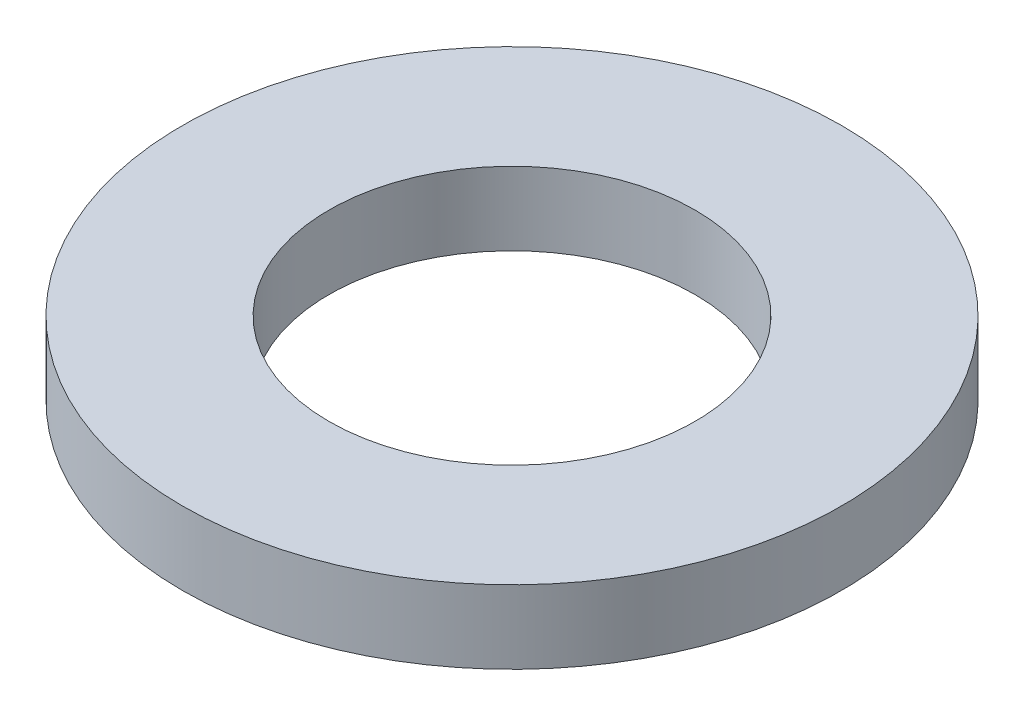
from build123d import *

# Parameters (mm, degrees)
SKETCH_1_R      = 4.5
SKETCH_1_R_2    = 2.5
EXTRUDE_1_DEPTH = 1


with BuildPart() as part:
    # 草图1 → 凸台-拉伸1 (new body)
    with BuildSketch(Plane(origin=(0, 0, 0), x_dir=(1, 0, 0), z_dir=(0, 1, 0))):
        Circle(SKETCH_1_R)
        Circle(SKETCH_1_R_2, mode=Mode.SUBTRACT)
    extrude(amount=EXTRUDE_1_DEPTH)


solid = part.part
